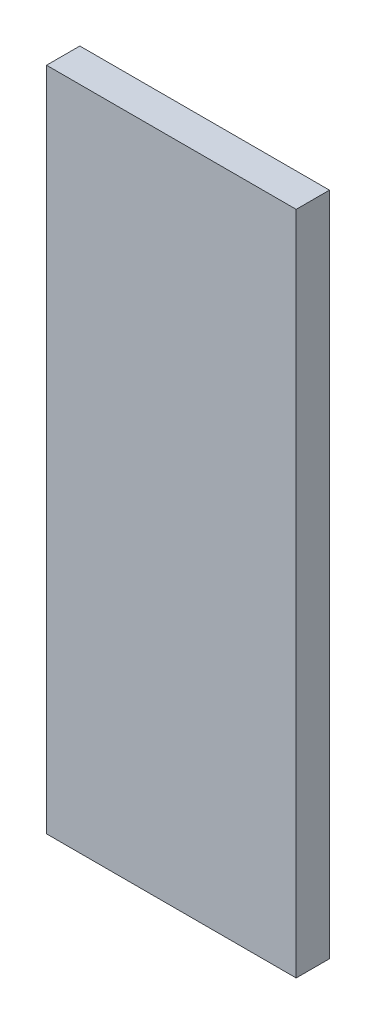
from build123d import *

# Parameters (mm, degrees)
SKETCH1_W           = 30
SKETCH1_H           = 80
BOSS_EXTRUDE1_DEPTH = 4


with BuildPart() as part:
    # Sketch1 → Boss-Extrude1 (new body)
    with BuildSketch(Plane.XY):
        Rectangle(SKETCH1_W, SKETCH1_H)
    extrude(amount=BOSS_EXTRUDE1_DEPTH)


solid = part.part
